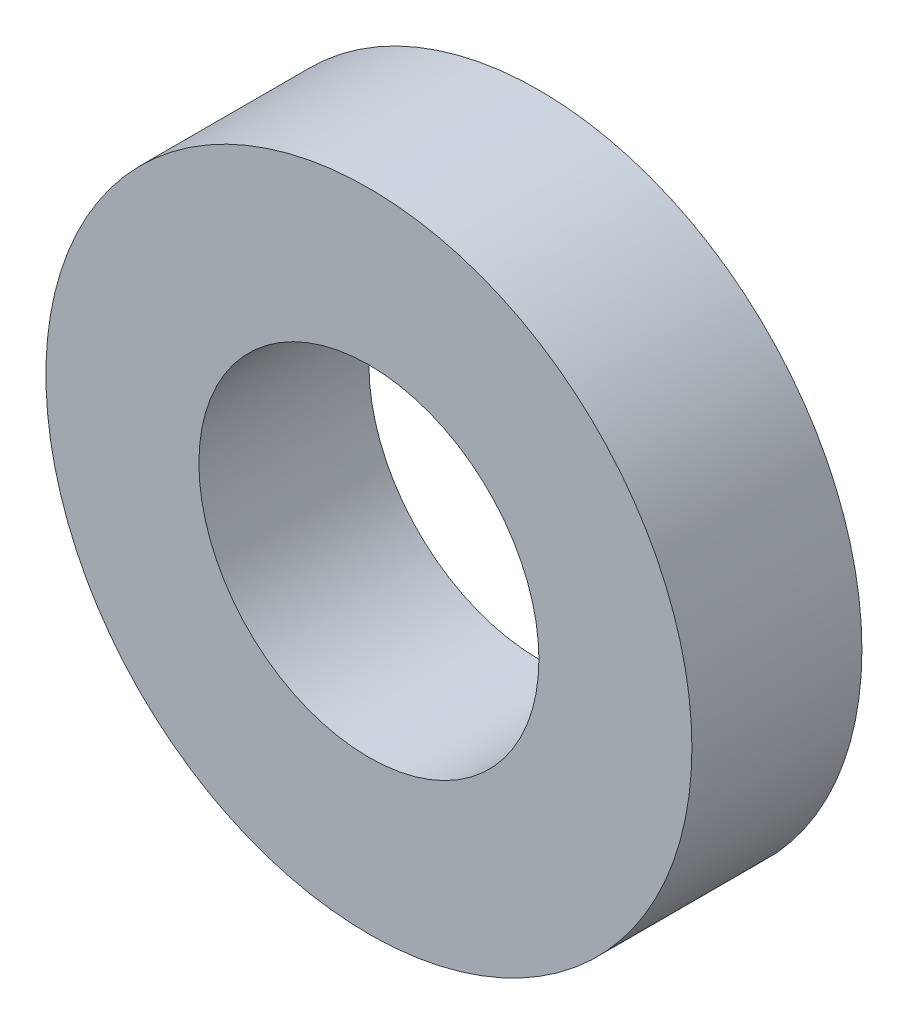
from build123d import *

# Parameters (mm, degrees)
SKETCH_1_R      = 9.5
SKETCH_1_R_2    = 5
EXTRUDE_1_DEPTH = 5


with BuildPart() as part:
    # 스케치1 → 보스-돌출1 (new body)
    with BuildSketch(Plane.XY):
        Circle(SKETCH_1_R)
        Circle(SKETCH_1_R_2, mode=Mode.SUBTRACT)
    extrude(amount=EXTRUDE_1_DEPTH)


solid = part.part
